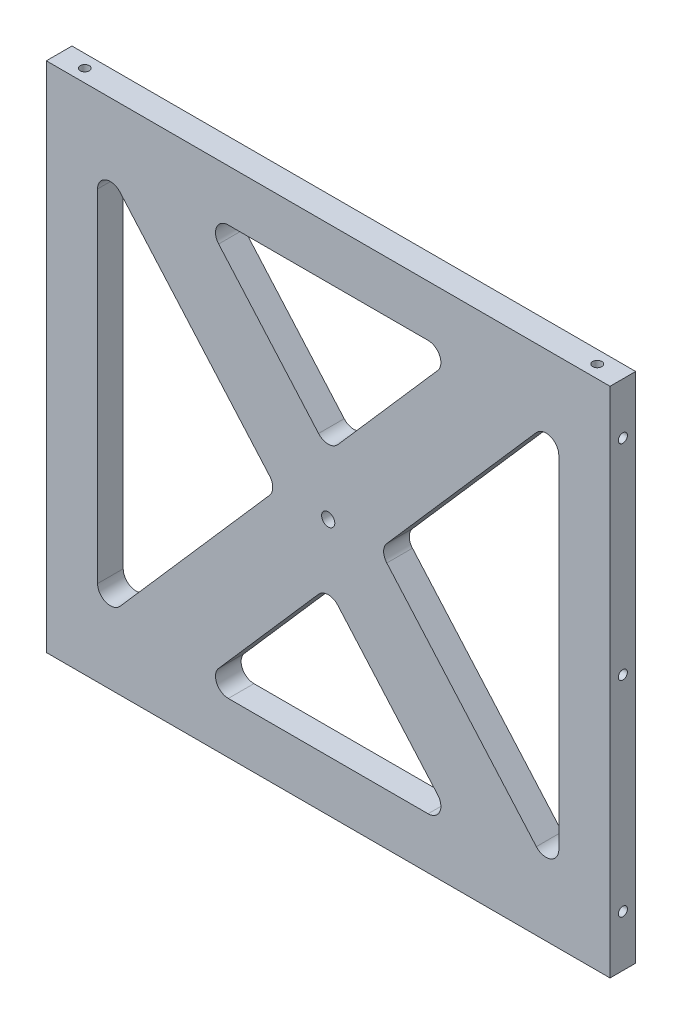
from build123d import *

# Parameters (mm, degrees)
SKETCH1_W                                      = 139.7
SKETCH1_H                                      = 127
BOSS_EXTRUDE1_DEPTH                            = 6.35
CUT_EXTRUDE1_DEPTH                             = 7.35
F_4_40_TAPPED_HOLE1_D                          = 2.2606
F_4_40_TAPPED_HOLE1_DEPTH                      = 7.5946
F_4_40_TAPPED_HOLE1_TIP                        = 0.679152758
F_4_40_TAPPED_HOLE2_D                          = 2.2606
F_4_40_TAPPED_HOLE2_DEPTH                      = 7.5946
F_4_40_TAPPED_HOLE2_TIP                        = 0.679152758
F_4_40_TAPPED_HOLE3_D                          = 2.2606
F_4_40_TAPPED_HOLE3_DEPTH                      = 7.5946
F_4_40_TAPPED_HOLE3_TIP                        = 0.679152758
CBORE_FOR_4_SOCKET_HEAD_CAP_SCREW1_D           = 3.2639
CBORE_FOR_4_SOCKET_HEAD_CAP_SCREW1_DEPTH       = 7.5946
CBORE_FOR_4_SOCKET_HEAD_CAP_SCREW1_CBORE_D     = 5.55752
CBORE_FOR_4_SOCKET_HEAD_CAP_SCREW1_CBORE_DEPTH = 2.8448
CBORE_FOR_4_SOCKET_HEAD_CAP_SCREW1_TIP         = 0.980574487
F_4_40_TAPPED_HOLE4_D                          = 2.2606
F_4_40_TAPPED_HOLE4_DEPTH                      = 7.5946
F_4_40_TAPPED_HOLE4_TIP                        = 0.679152758
FILLET1_R                                      = 3.175


with BuildPart() as part:
    # Sketch1 → Boss-Extrude1 (new body)
    with BuildSketch(Plane.XY):
        Rectangle(SKETCH1_W, SKETCH1_H)
    extrude(amount=BOSS_EXTRUDE1_DEPTH)

    # Sketch2 → Cut-Extrude1 (cut, through all)
    with BuildSketch(Plane.XY.offset(6.35)):
        Polygon((-57.15, 50.8), (-57.15, -50.8), (-12.7, 0), align=None)
        Polygon((57.15, 50.8), (57.15, -50.8), (12.7, 0), align=None)
        Polygon((-31.75, 50.8), (31.75, 50.8), (0, 14.514285714), align=None)
        Polygon((31.75, -50.8), (0, -14.514285714), (-31.75, -50.8), align=None)
    extrude(amount=-CUT_EXTRUDE1_DEPTH, mode=Mode.SUBTRACT)

    # #4-40 Tapped Hole1
    with Locations(Plane(origin=(0, -63.5, 0), x_dir=(-1, 0, 0), z_dir=(0, -1, 0))):
        with Locations((-63.5, -3.175), (63.5, -3.175)):
            Hole(F_4_40_TAPPED_HOLE1_D / 2, depth=F_4_40_TAPPED_HOLE1_DEPTH)
            with Locations((0, 0, -(F_4_40_TAPPED_HOLE1_DEPTH + F_4_40_TAPPED_HOLE1_TIP / 2))):  # 118° drill point
                Cone(0, F_4_40_TAPPED_HOLE1_D / 2, F_4_40_TAPPED_HOLE1_TIP, mode=Mode.SUBTRACT)

    # #4-40 Tapped Hole2
    with Locations(Plane.ZY.offset(69.85)):
        with Locations((3.175, 0), (3.175, 50.8), (3.175, -50.8)):
            Hole(F_4_40_TAPPED_HOLE2_D / 2, depth=F_4_40_TAPPED_HOLE2_DEPTH)
            with Locations((0, 0, -(F_4_40_TAPPED_HOLE2_DEPTH + F_4_40_TAPPED_HOLE2_TIP / 2))):  # 118° drill point
                Cone(0, F_4_40_TAPPED_HOLE2_D / 2, F_4_40_TAPPED_HOLE2_TIP, mode=Mode.SUBTRACT)

    # #4-40 Tapped Hole3
    with Locations(Plane(origin=(69.85, 0, 0), x_dir=(0, 0, -1), z_dir=(1, 0, 0))):
        with Locations((-3.175, 50.8), (-3.175, 0), (-3.175, -50.8)):
            Hole(F_4_40_TAPPED_HOLE3_D / 2, depth=F_4_40_TAPPED_HOLE3_DEPTH)
            with Locations((0, 0, -(F_4_40_TAPPED_HOLE3_DEPTH + F_4_40_TAPPED_HOLE3_TIP / 2))):  # 118° drill point
                Cone(0, F_4_40_TAPPED_HOLE3_D / 2, F_4_40_TAPPED_HOLE3_TIP, mode=Mode.SUBTRACT)

    # CBORE for #4 Socket Head Cap Screw1
    with Locations(Plane(origin=(0, 0, 0), x_dir=(-1, 0, 0), z_dir=(0, 0, -1))):
        with Locations((0, 0)):
            CounterBoreHole(CBORE_FOR_4_SOCKET_HEAD_CAP_SCREW1_D / 2, CBORE_FOR_4_SOCKET_HEAD_CAP_SCREW1_CBORE_D / 2, CBORE_FOR_4_SOCKET_HEAD_CAP_SCREW1_CBORE_DEPTH, depth=CBORE_FOR_4_SOCKET_HEAD_CAP_SCREW1_DEPTH)
            with Locations((0, 0, -(CBORE_FOR_4_SOCKET_HEAD_CAP_SCREW1_DEPTH + CBORE_FOR_4_SOCKET_HEAD_CAP_SCREW1_TIP / 2))):  # 118° drill point
                Cone(0, CBORE_FOR_4_SOCKET_HEAD_CAP_SCREW1_D / 2, CBORE_FOR_4_SOCKET_HEAD_CAP_SCREW1_TIP, mode=Mode.SUBTRACT)

    # #4-40 Tapped Hole4
    with Locations(Plane(origin=(0, 63.5, 0), x_dir=(1, 0, 0), z_dir=(0, 1, 0))):
        with Locations((-63.5, -3.175), (63.5, -3.175)):
            Hole(F_4_40_TAPPED_HOLE4_D / 2, depth=F_4_40_TAPPED_HOLE4_DEPTH)
            with Locations((0, 0, -(F_4_40_TAPPED_HOLE4_DEPTH + F_4_40_TAPPED_HOLE4_TIP / 2))):  # 118° drill point
                Cone(0, F_4_40_TAPPED_HOLE4_D / 2, F_4_40_TAPPED_HOLE4_TIP, mode=Mode.SUBTRACT)

    # Fillet1
    fillet1_edges = [part.edges().sort_by_distance(p)[0] for p in [
        (0, 14.514285714, 3.175),
        (-31.75, 50.8, 3.175),
        (31.75, 50.8, 3.175),
        (31.75, -50.8, 3.175),
        (-31.75, -50.8, 3.175),
        (0, -14.514285714, 3.175),
        (12.7, 0, 3.175),
        (57.15, 50.8, 3.175),
        (57.15, -50.8, 3.175),
        (-57.15, 50.8, 3.175),
        (-12.7, 0, 3.175),
        (-57.15, -50.8, 3.175),
    ]]
    fillet(fillet1_edges, radius=FILLET1_R)


solid = part.part
